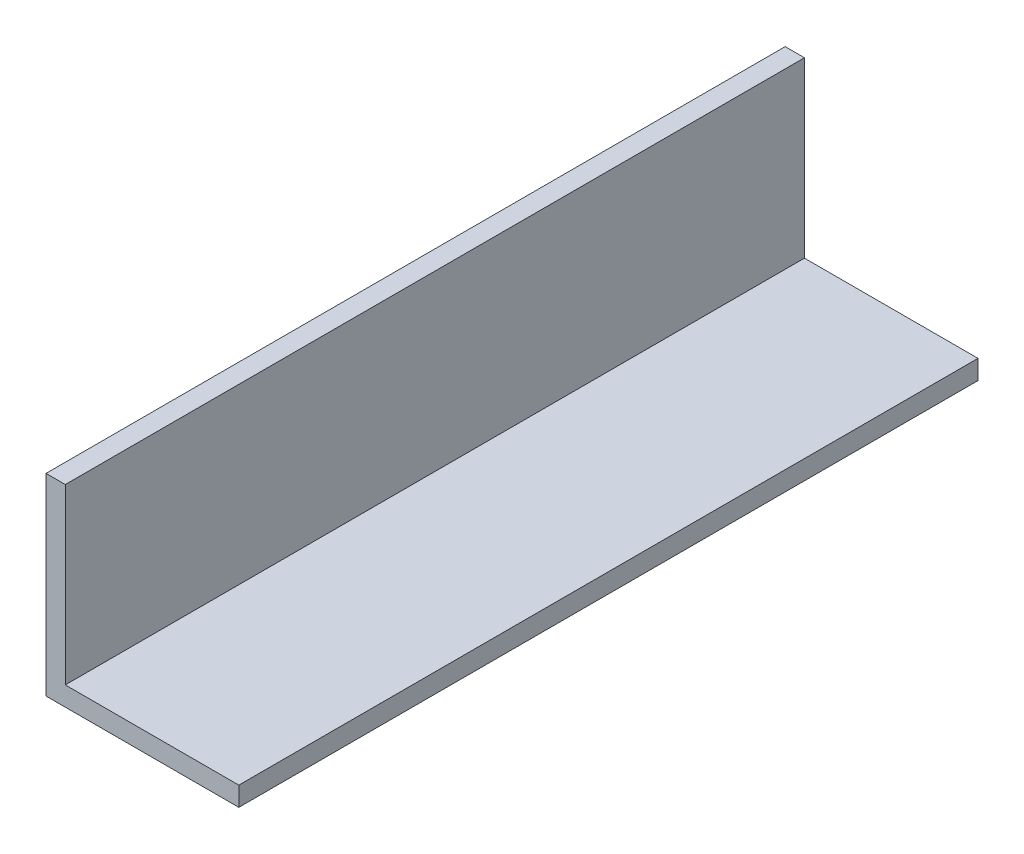
from build123d import *

# Parameters (mm, degrees)
EXTRUDE_1_DEPTH = 115


with BuildPart() as part:
    # Эскиз1 → Бобышка-Вытянуть1 (new body)
    with BuildSketch(Plane.XY):
        Polygon((0, 30), (0, 0), (30, 0), (30, 3), (3, 3), (3, 30), align=None)
    extrude(amount=EXTRUDE_1_DEPTH)


solid = part.part
